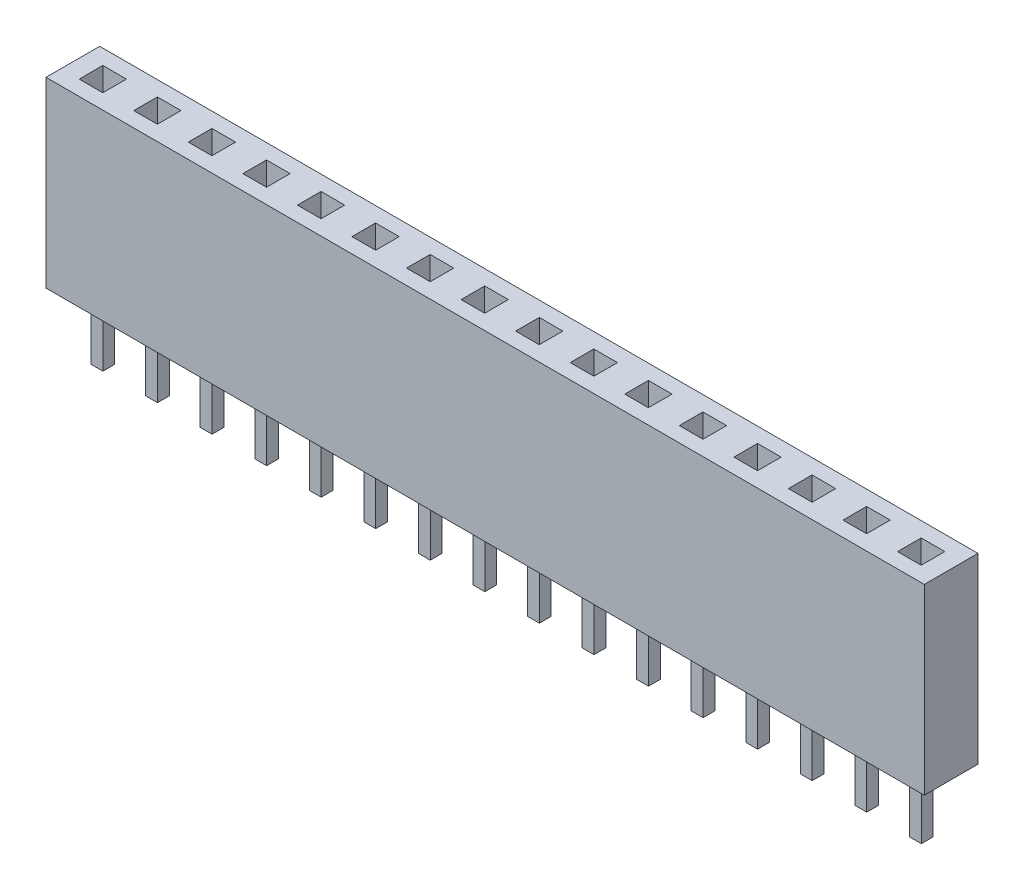
from build123d import *

# Parameters (mm, degrees)
SKETCH1_W              = 40.89
SKETCH1_H              = 8.5
BOSS_EXTRUDE1_DEPTH    = 1.25
SKETCH2_W              = 1.1
SKETCH2_H              = 1.1
CUT_EXTRUDE1_DEPTH     = 42.782826616
SKETCH3_W              = 40.89
SKETCH3_H              = 2.5
BOSS_EXTRUDE2_DEPTH    = 1
SKETCH4_W              = 0.55
SKETCH4_H              = 0.55
BOSS_EXTRUDE3_DEPTH    = 3
BOSS_EXTRUDE3_2_DEPTH  = 3
BOSS_EXTRUDE3_3_DEPTH  = 3
BOSS_EXTRUDE3_4_DEPTH  = 3
BOSS_EXTRUDE3_5_DEPTH  = 3
BOSS_EXTRUDE3_6_DEPTH  = 3
BOSS_EXTRUDE3_7_DEPTH  = 3
BOSS_EXTRUDE3_8_DEPTH  = 3
BOSS_EXTRUDE3_9_DEPTH  = 3
BOSS_EXTRUDE3_10_DEPTH = 3
BOSS_EXTRUDE3_11_DEPTH = 3
BOSS_EXTRUDE3_12_DEPTH = 3
BOSS_EXTRUDE3_13_DEPTH = 3
BOSS_EXTRUDE3_14_DEPTH = 3
BOSS_EXTRUDE3_15_DEPTH = 3
BOSS_EXTRUDE3_16_DEPTH = 3


with BuildPart() as part:
    # Sketch1 → Boss-Extrude1 (new, symmetric)
    with BuildSketch(Plane.XY):
        with Locations((20.445, 4.25)):
            Rectangle(SKETCH1_W, SKETCH1_H)
    extrude(amount=BOSS_EXTRUDE1_DEPTH, both=True)

    # Sketch2 → Cut-Extrude1 (cut, through all)
    with BuildSketch(Plane.XZ):
        with Locations((3.935, 0)):
            Rectangle(SKETCH2_W, SKETCH2_H)
        with Locations((1.395, 0)):
            Rectangle(SKETCH2_W, SKETCH2_H)
        with Locations((6.475, 0)):
            Rectangle(SKETCH2_W, SKETCH2_H)
        with Locations((9.015, 0)):
            Rectangle(SKETCH2_W, SKETCH2_H)
        with Locations((11.555, 0)):
            Rectangle(SKETCH2_W, SKETCH2_H)
        with Locations((14.095, 0)):
            Rectangle(SKETCH2_W, SKETCH2_H)
        with Locations((16.635, 0)):
            Rectangle(SKETCH2_W, SKETCH2_H)
        with Locations((19.175, 0)):
            Rectangle(SKETCH2_W, SKETCH2_H)
        with Locations((21.715, 0)):
            Rectangle(SKETCH2_W, SKETCH2_H)
        with Locations((24.255, 0)):
            Rectangle(SKETCH2_W, SKETCH2_H)
        with Locations((26.795, 0)):
            Rectangle(SKETCH2_W, SKETCH2_H)
        with Locations((29.335, 0)):
            Rectangle(SKETCH2_W, SKETCH2_H)
        with Locations((31.875, 0)):
            Rectangle(SKETCH2_W, SKETCH2_H)
        with Locations((34.415, 0)):
            Rectangle(SKETCH2_W, SKETCH2_H)
        with Locations((36.955, 0)):
            Rectangle(SKETCH2_W, SKETCH2_H)
        with Locations((39.495, 0)):
            Rectangle(SKETCH2_W, SKETCH2_H)
    extrude(amount=-CUT_EXTRUDE1_DEPTH, mode=Mode.SUBTRACT)

    # Sketch3 → Boss-Extrude2 (add)
    with BuildSketch(Plane.XZ):
        with Locations((20.445, 0)):
            Rectangle(SKETCH3_W, SKETCH3_H)
    extrude(amount=-BOSS_EXTRUDE2_DEPTH)


with BuildPart() as body_2:
    # Sketch4 → Boss-Extrude3 (new body)
    with BuildSketch(Plane.XZ):
        with Locations((1.4, 0)):
            Rectangle(SKETCH4_W, SKETCH4_H)
    extrude(amount=BOSS_EXTRUDE3_DEPTH)


with BuildPart() as body_3:
    # Sketch4 → Boss-Extrude3 2 (new body)
    with BuildSketch(Plane.XZ):
        with Locations((3.94, 0)):
            Rectangle(SKETCH4_W, SKETCH4_H)
    extrude(amount=BOSS_EXTRUDE3_2_DEPTH)


with BuildPart() as body_4:
    # Sketch4 → Boss-Extrude3 3 (new body)
    with BuildSketch(Plane.XZ):
        with Locations((6.48, 0)):
            Rectangle(SKETCH4_W, SKETCH4_H)
    extrude(amount=BOSS_EXTRUDE3_3_DEPTH)


with BuildPart() as body_5:
    # Sketch4 → Boss-Extrude3 4 (new body)
    with BuildSketch(Plane.XZ):
        with Locations((9.02, 0)):
            Rectangle(SKETCH4_W, SKETCH4_H)
    extrude(amount=BOSS_EXTRUDE3_4_DEPTH)


with BuildPart() as body_6:
    # Sketch4 → Boss-Extrude3 5 (new body)
    with BuildSketch(Plane.XZ):
        with Locations((11.56, 0)):
            Rectangle(SKETCH4_W, SKETCH4_H)
    extrude(amount=BOSS_EXTRUDE3_5_DEPTH)


with BuildPart() as body_7:
    # Sketch4 → Boss-Extrude3 6 (new body)
    with BuildSketch(Plane.XZ):
        with Locations((14.1, 0)):
            Rectangle(SKETCH4_W, SKETCH4_H)
    extrude(amount=BOSS_EXTRUDE3_6_DEPTH)


with BuildPart() as body_8:
    # Sketch4 → Boss-Extrude3 7 (new body)
    with BuildSketch(Plane.XZ):
        with Locations((16.64, 0)):
            Rectangle(SKETCH4_W, SKETCH4_H)
    extrude(amount=BOSS_EXTRUDE3_7_DEPTH)


with BuildPart() as body_9:
    # Sketch4 → Boss-Extrude3 8 (new body)
    with BuildSketch(Plane.XZ):
        with Locations((19.18, 0)):
            Rectangle(SKETCH4_W, SKETCH4_H)
    extrude(amount=BOSS_EXTRUDE3_8_DEPTH)


with BuildPart() as body_10:
    # Sketch4 → Boss-Extrude3 9 (new body)
    with BuildSketch(Plane.XZ):
        with Locations((21.72, 0)):
            Rectangle(SKETCH4_W, SKETCH4_H)
    extrude(amount=BOSS_EXTRUDE3_9_DEPTH)


with BuildPart() as body_11:
    # Sketch4 → Boss-Extrude3 10 (new body)
    with BuildSketch(Plane.XZ):
        with Locations((24.26, 0)):
            Rectangle(SKETCH4_W, SKETCH4_H)
    extrude(amount=BOSS_EXTRUDE3_10_DEPTH)


with BuildPart() as body_12:
    # Sketch4 → Boss-Extrude3 11 (new body)
    with BuildSketch(Plane.XZ):
        with Locations((26.8, 0)):
            Rectangle(SKETCH4_W, SKETCH4_H)
    extrude(amount=BOSS_EXTRUDE3_11_DEPTH)


with BuildPart() as body_13:
    # Sketch4 → Boss-Extrude3 12 (new body)
    with BuildSketch(Plane.XZ):
        with Locations((29.34, 0)):
            Rectangle(SKETCH4_W, SKETCH4_H)
    extrude(amount=BOSS_EXTRUDE3_12_DEPTH)


with BuildPart() as body_14:
    # Sketch4 → Boss-Extrude3 13 (new body)
    with BuildSketch(Plane.XZ):
        with Locations((31.88, 0)):
            Rectangle(SKETCH4_W, SKETCH4_H)
    extrude(amount=BOSS_EXTRUDE3_13_DEPTH)


with BuildPart() as body_15:
    # Sketch4 → Boss-Extrude3 14 (new body)
    with BuildSketch(Plane.XZ):
        with Locations((34.42, 0)):
            Rectangle(SKETCH4_W, SKETCH4_H)
    extrude(amount=BOSS_EXTRUDE3_14_DEPTH)


with BuildPart() as body_16:
    # Sketch4 → Boss-Extrude3 15 (new body)
    with BuildSketch(Plane.XZ):
        with Locations((36.96, 0)):
            Rectangle(SKETCH4_W, SKETCH4_H)
    extrude(amount=BOSS_EXTRUDE3_15_DEPTH)


with BuildPart() as body_17:
    # Sketch4 → Boss-Extrude3 16 (new body)
    with BuildSketch(Plane.XZ):
        with Locations((39.5, 0)):
            Rectangle(SKETCH4_W, SKETCH4_H)
    extrude(amount=BOSS_EXTRUDE3_16_DEPTH)


solid = Compound([part.part, body_2.part, body_3.part, body_4.part, body_5.part, body_6.part, body_7.part, body_8.part, body_9.part, body_10.part, body_11.part, body_12.part, body_13.part, body_14.part, body_15.part, body_16.part, body_17.part])
